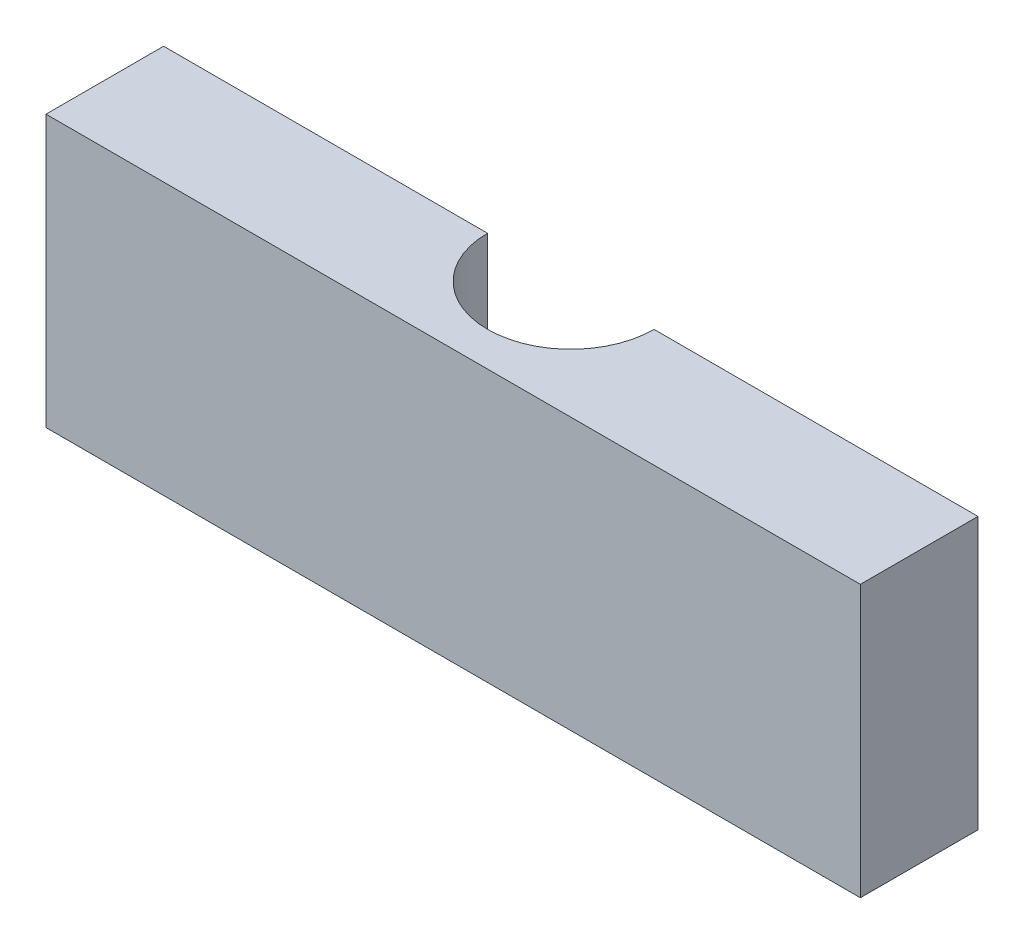
from build123d import *

# Parameters (mm, degrees)
SKETCH_1_W          = 45
SKETCH_1_H          = 15
EXTRUDE_1_DEPTH     = 6.5
SKETCH_3_R          = 4.6
CUT_EXTRUDE_1_DEPTH = 16


with BuildPart() as part:
    # 草图1 → 凸台-拉伸1 (new body)
    with BuildSketch(Plane.XY):
        with Locations((8.502087683, -5.292275574)):
            Rectangle(SKETCH_1_W, SKETCH_1_H)
    extrude(amount=EXTRUDE_1_DEPTH)

    # 草图3 → 切除-拉伸1 (cut, through all)
    with BuildSketch(Plane(origin=(0, 2.207724426, 0), x_dir=(1, 0, 0), z_dir=(0, 1, 0))):
        with Locations((8.502087683, 0)):
            Circle(SKETCH_3_R)
    extrude(amount=-CUT_EXTRUDE_1_DEPTH, mode=Mode.SUBTRACT)


solid = part.part
